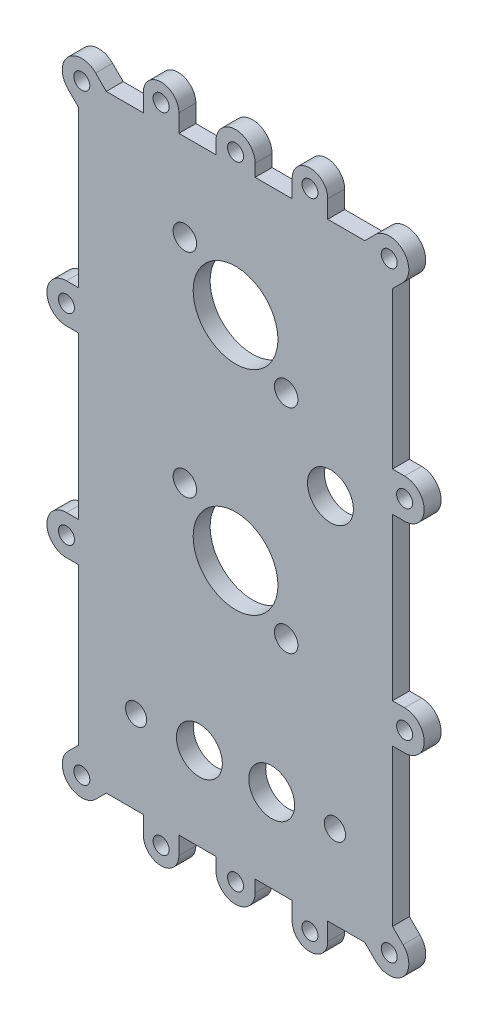
from build123d import *

# Parameters (mm, degrees)
BOSS_EXTRUDE1_DEPTH  = 4.7625
M4_CLEARANCE_HOLE1_D = 4.5
SKETCH4_R            = 3.3
SKETCH4_R_2          = 2.9765625
SKETCH4_R_3          = 6.445
SKETCH4_R_4          = 11.9
CUT_EXTRUDE1_DEPTH   = 4.7625
BOSS_EXTRUDE3_DEPTH  = 4.7625
M4_CLEARANCE_HOLE2_D = 4.5


with BuildPart() as part:
    # Sketch1 → Boss-Extrude1 (new body)
    with BuildSketch(Plane.XY):
        with BuildLine():
            Line((50.349976536, 7.779015878), (19.528151129, 7.779015878))
            Line((19.528151129, 7.779015878), (16.547693582, 10.759473425))
            ThreePointArc((16.547693582, 10.759473425), (8.769518989, 10.759473425), (8.769518989, 2.981298831))
            Line((8.769518989, 2.981298831), (11.749976536, 0.000841285))
            Line((11.749976536, 0.000841285), (11.749976536, -43.901984122))
            Line((11.749976536, -43.901984122), (8.340276536, -43.901984122))
            ThreePointArc((8.340276536, -43.901984122), (2.840276536, -49.401984122), (8.340276536, -54.901984122))
            Line((8.340276536, -54.901984122), (11.749976536, -54.901984122))
            Line((11.749976536, -54.901984122), (11.749976536, -100.289984122))
            Line((11.749976536, -100.289984122), (8.340276536, -100.289984122))
            ThreePointArc((8.340276536, -100.289984122), (2.840276536, -105.789984122), (8.340276536, -111.289984122))
            Line((8.340276536, -111.289984122), (11.749976536, -111.289984122))
            Line((11.749976536, -111.289984122), (11.749976536, -155.192809529))
            Line((11.749976536, -155.192809529), (8.769518989, -158.173267075))
            ThreePointArc((8.769518989, -158.173267075), (8.769518989, -165.951441668), (16.547693582, -165.951441668))
            Line((16.547693582, -165.951441668), (19.528151129, -162.970984122))
            Line((19.528151129, -162.970984122), (50.349976536, -162.970984122))
            Line((50.349976536, -162.970984122), (50.349976536, -166.380684122))
            ThreePointArc((50.349976536, -166.380684122), (55.849976536, -171.880684122), (61.349976536, -166.380684122))
            Line((61.349976536, -166.380684122), (61.349976536, -162.970984122))
            Line((61.349976536, -162.970984122), (92.171801943, -162.970984122))
            Line((92.171801943, -162.970984122), (95.152259489, -165.951441668))
            ThreePointArc((95.152259489, -165.951441668), (102.930434082, -165.951441668), (102.930434082, -158.173267075))
            Line((102.930434082, -158.173267075), (99.949976536, -155.192809529))
            Line((99.949976536, -155.192809529), (99.949976536, -111.289984122))
            Line((99.949976536, -111.289984122), (103.359676536, -111.289984122))
            ThreePointArc((103.359676536, -111.289984122), (108.859676536, -105.789984122), (103.359676536, -100.289984122))
            Line((103.359676536, -100.289984122), (99.949976536, -100.289984122))
            Line((99.949976536, -100.289984122), (99.949976536, -54.901984122))
            Line((99.949976536, -54.901984122), (103.359676536, -54.901984122))
            ThreePointArc((103.359676536, -54.901984122), (108.859676536, -49.401984122), (103.359676536, -43.901984122))
            Line((103.359676536, -43.901984122), (99.949976536, -43.901984122))
            Line((99.949976536, -43.901984122), (99.949976536, 0.000841285))
            Line((99.949976536, 0.000841285), (102.930434082, 2.981298831))
            ThreePointArc((102.930434082, 2.981298831), (102.930434082, 10.759473425), (95.152259489, 10.759473425))
            Line((95.152259489, 10.759473425), (92.171801943, 7.779015878))
            Line((92.171801943, 7.779015878), (61.349976536, 7.779015878))
            Line((61.349976536, 7.779015878), (61.349976536, 11.188715878))
            ThreePointArc((61.349976536, 11.188715878), (55.849976536, 16.688715878), (50.349976536, 11.188715878))
            Line((50.349976536, 11.188715878), (50.349976536, 7.779015878))
        make_face()
    extrude(amount=-BOSS_EXTRUDE1_DEPTH)

    # M4 Clearance Hole1 (through all)
    with Locations(Plane(origin=(0, 0, -4.7625), x_dir=(-1, 0, 0), z_dir=(0, 0, -1))):
        with Locations((-12.658606286, -162.062354372), (-55.849976536, -166.380684122), (-99.041346785, -162.062354372), (-103.359676536, -105.789984122), (-103.359676536, -49.401984122), (-99.041346785, 6.870386128), (-12.658606286, 6.870386128), (-8.340276536, -49.401984122), (-8.340276536, -105.789984122), (-55.849976536, 11.188715878)):
            Hole(M4_CLEARANCE_HOLE1_D / 2)

    # Sketch4 → Cut-Extrude1 (cut)
    with BuildSketch(Plane(origin=(0, 0, -4.7625), x_dir=(-1, 0, 0), z_dir=(0, 0, -1))):
        with Locations((-41.616084767, -16.665859852)):
            Circle(SKETCH4_R)
        with Locations((-70.083868304, -40.3002691)):
            Circle(SKETCH4_R)
        with Locations((-27.909976536, -139.508484122)):
            Circle(SKETCH4_R_2)
        with Locations((-41.616084767, -76.466699143)):
            Circle(SKETCH4_R)
        with Locations((-83.789976536, -139.508484122)):
            Circle(SKETCH4_R_2)
        with Locations((-70.083868304, -100.101108391)):
            Circle(SKETCH4_R)
        with Locations((-66.009976536, -139.508484122)):
            Circle(SKETCH4_R_3)
        with Locations((-82.519976536, -59.220984122)):
            Circle(SKETCH4_R_3)
        with Locations((-45.689976536, -139.508484122)):
            Circle(SKETCH4_R_3)
        with Locations((-55.849976536, -88.283903767)):
            Circle(SKETCH4_R_4)
        with Locations((-55.849976536, -28.483064476)):
            Circle(SKETCH4_R_4)
    extrude(amount=-CUT_EXTRUDE1_DEPTH, mode=Mode.SUBTRACT)

    # Sketch6 → Boss-Extrude3 (add)
    with BuildSketch(Plane.XY):
        with BuildLine():
            ThreePointArc((39.939063832, 12.779015878), (34.939063832, 17.779015878), (29.939063832, 12.779015878))
            Line((29.939063832, 12.779015878), (29.939063832, 7.779015878))
            Line((29.939063832, 7.779015878), (39.939063832, 7.779015878))
            Line((39.939063832, 7.779015878), (39.939063832, 12.779015878))
        make_face()
        with BuildLine():
            Line((81.760889239, -162.970984122), (71.760889239, -162.970984122))
            Line((71.760889239, -162.970984122), (71.760889239, -167.970984122))
            ThreePointArc((71.760889239, -167.970984122), (76.760889239, -172.970984122), (81.760889239, -167.970984122))
            Line((81.760889239, -167.970984122), (81.760889239, -162.970984122))
        make_face()
    boss_extrude3 = extrude(amount=-BOSS_EXTRUDE3_DEPTH)

    # M4 Clearance Hole2 (through all)
    with Locations(Plane.XY):
        with Locations((34.939063832, 12.779015878), (76.760889239, -167.970984122)):
            m4_clearance_hole2 = Hole(M4_CLEARANCE_HOLE2_D / 2)

    # Mirror1: Boss-Extrude3, M4 Clearance Hole2 across plane
    add(boss_extrude3.mirror(Plane.ZY.offset(-55.849976536)))
    add(m4_clearance_hole2.mirror(Plane.ZY.offset(-55.849976536)), mode=Mode.SUBTRACT)


solid = part.part
